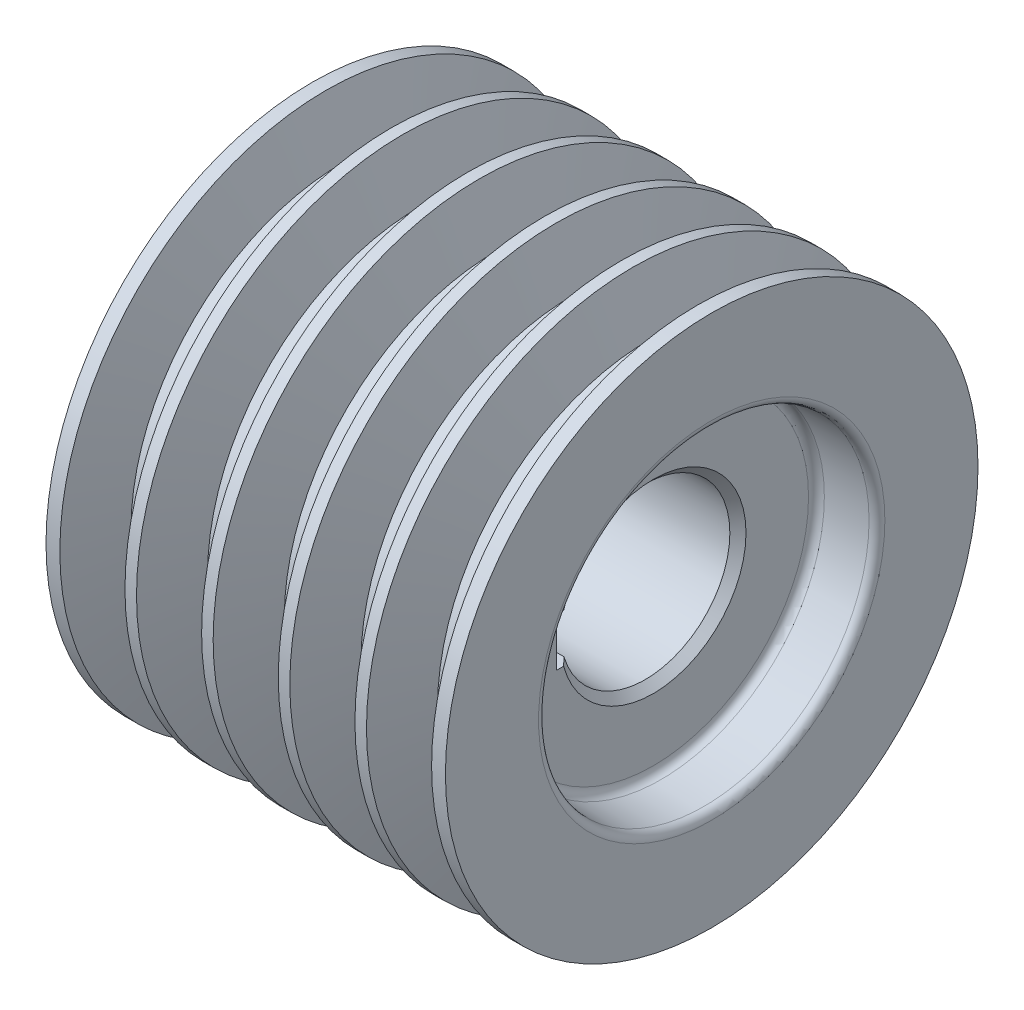
from build123d import *

# Parameters (mm, degrees)
SKETCH_1_W               = 99
SKETCH_1_H               = 66
SKETCH_2_R               = 41
CUT_EXTRUDE_1_DEPTH      = 14.5
CUT_EXTRUDE_1_DRAFT      = -2.29
MIRROR_1_COPY_1_SKETCH_R = 41
MIRROR_1_COPY_1_DEPTH    = 14.5
MIRROR_1_COPY_1_DRAFT    = -2.29
FILLET_1_R               = 2
PATTERN_LINEAR_1_COUNT   = 3
PATTERN_LINEAR_1_PITCH   = 19
PATTERN_LINEAR_2_COUNT   = 2
PATTERN_LINEAR_2_PITCH   = 57
PATTERN_LINEAR_3_COUNT   = 2
PATTERN_LINEAR_3_PITCH   = 76
SKETCH_5_R               = 21
CUT_EXTRUDE_2_DEPTH      = 139.008429752
CHAMFER_1_SIZE           = 2
SKETCH_6_W               = 24
SKETCH_6_H               = 12
CUT_EXTRUDE_3_DEPTH      = 139.008429752


with BuildPart() as part:
    # 草图1 → 旋转1 (revolve)
    with BuildSketch(Plane.XY):
        with Locations((30.45222636, 12.108822758)):
            Rectangle(SKETCH_1_W, SKETCH_1_H)
    revolve(axis=Axis((-19.04777364, -20.891177242, 0), (1, 0, 0)))


with BuildPart() as cut_extrude_1_tool:
    # 草图2 → 切除-拉伸1 (with draft: the straight prism first)
    with BuildSketch(Plane.ZY.offset(19.04777364)):
        with Locations((0, -20.891177242)):
            Circle(SKETCH_2_R)
    extrude(amount=-CUT_EXTRUDE_1_DEPTH)
    # 切除-拉伸1: the draft: its side faces are tilted about the plane it starts from
    cut_extrude_1_sides = [cut_extrude_1_tool.faces().sort_by_distance(p)[0] for p in [
        (-11.79777364, -20.891177242, -41),
    ]]
    draft(cut_extrude_1_sides, Plane.ZY.offset(19.04777364), CUT_EXTRUDE_1_DRAFT)


with BuildPart() as part_1:
    add(part.part)

    # 切除-拉伸1: cut by cut_extrude_1_tool
    add(cut_extrude_1_tool.part, mode=Mode.SUBTRACT)


with BuildPart() as mirror_1_copy_1_tool:
    # 镜向1 copy 1 sketch → 镜向1 copy 1 (with draft: the straight prism first)
    with BuildSketch(Plane(origin=(79.95222636, 0, 0), x_dir=(0, 0, 1), z_dir=(1, 0, 0))):
        with Locations((0, 20.891177242)):
            Circle(MIRROR_1_COPY_1_SKETCH_R)
    extrude(amount=-MIRROR_1_COPY_1_DEPTH)
    # 镜向1 copy 1: the draft: its side faces are tilted about the plane it starts from
    mirror_1_copy_1_sides = [mirror_1_copy_1_tool.faces().sort_by_distance(p)[0] for p in [
        (72.70222636, -20.891177242, -41),
    ]]
    draft(mirror_1_copy_1_sides, Plane(origin=(79.95222636, 0, 0), x_dir=(0, 0, 1), z_dir=(1, 0, 0)), MIRROR_1_COPY_1_DRAFT)


with BuildPart() as part_2:
    add(part_1.part)

    # 镜向1 copy 1: cut by mirror_1_copy_1_tool
    add(mirror_1_copy_1_tool.part, mode=Mode.SUBTRACT)

    # 圆角1
    fillet_1_edges = [part_2.edges().sort_by_distance(p)[0] for p in [
        (-4.54777364, -20.891177242, -40.420154632),
        (-19.04777364, -20.891177242, -41),
        (65.45222636, -20.891177242, -40.420154632),
        (79.95222636, -20.891177242, -41),
    ]]
    fillet(fillet_1_edges, radius=FILLET_1_R)

    # 切除-扫描1: sweep along a path in 草图4
    with BuildLine(Plane(origin=(72.394919545, 31.608822758, 0), x_dir=(0, 0, -1), z_dir=(1, 0, 0))) as sweep_1_path:
        CenterArc((0, -52.5), 52.5, 0, 360)
    # 草图3 → 切除-扫描1 (sweep, cut)
    with BuildSketch(Plane.XY):
        Polygon((64.509533174, 31.608822758), (72.394919545, 31.608822758), (76.522283745, 45.108822758), (60.382168975, 45.108822758), align=None)
    sweep_1 = sweep(path=sweep_1_path.line, mode=Mode.SUBTRACT)

    # 阵列(线性)1: 切除-扫描1 ×3
    with Locations(*[(-i * PATTERN_LINEAR_1_PITCH, 0, 0) for i in range(1, PATTERN_LINEAR_1_COUNT)]):
        add(sweep_1, mode=Mode.SUBTRACT)

    # 阵列(线性)2: 切除-扫描1 ×2
    with Locations(*[(-i * PATTERN_LINEAR_2_PITCH, 0, 0) for i in range(1, PATTERN_LINEAR_2_COUNT)]):
        add(sweep_1, mode=Mode.SUBTRACT)

    # 阵列(线性)3: 切除-扫描1 ×2
    with Locations(*[(-i * PATTERN_LINEAR_3_PITCH, 0, 0) for i in range(1, PATTERN_LINEAR_3_COUNT)]):
        add(sweep_1, mode=Mode.SUBTRACT)

    # 草图5 → 切除-拉伸2 (cut, through all)
    with BuildSketch(Plane.ZY.offset(4.54777364)):
        with Locations((0, -20.891177242)):
            Circle(SKETCH_5_R)
    extrude(amount=-CUT_EXTRUDE_2_DEPTH, mode=Mode.SUBTRACT)

    # 倒角1
    chamfer_1_edges = [part_2.edges().sort_by_distance(p)[0] for p in [
        (65.45222636, -20.891177242, -21),
        (-4.54777364, -20.891177242, -21),
    ]]
    chamfer(chamfer_1_edges, length=CHAMFER_1_SIZE)

    # 草图6 → 切除-拉伸3 (cut, through all)
    with BuildSketch(Plane(origin=(65.45222636, 0, 0), x_dir=(0, 0, -1), z_dir=(1, 0, 0))):
        with Locations((-12, -20.891177242)):
            Rectangle(SKETCH_6_W, SKETCH_6_H)
    extrude(amount=-CUT_EXTRUDE_3_DEPTH, mode=Mode.SUBTRACT)


solid = part_2.part
